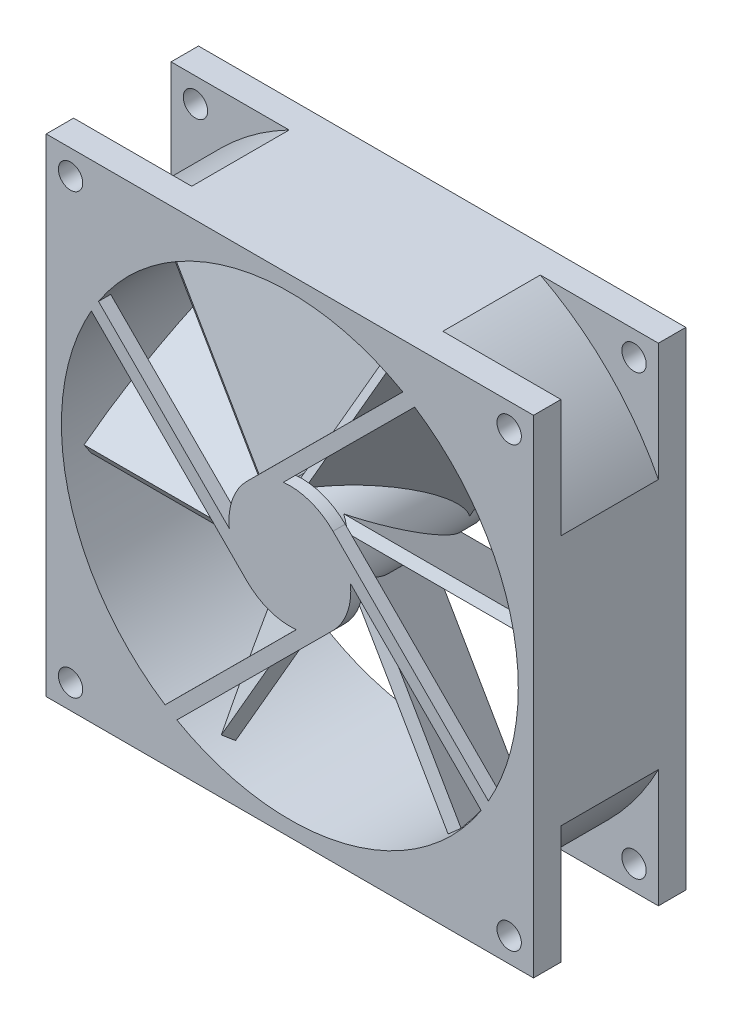
from build123d import *

# Parameters (mm, degrees)
SKETCH1_W                = 80
SKETCH1_H                = 80
SKETCH1_R                = 37.5
BOSS_EXTRUDE1_DEPTH      = 12.5
BOSS_EXTRUDE1_DEPTH_BACK = 12.5
SKETCH2_R                = 60
SKETCH2_R_2              = 45
CUT_EXTRUDE1_DEPTH       = 8
CUT_EXTRUDE1_DEPTH_BACK  = 8
SKETCH3_R                = 2
CUT_EXTRUDE2_DEPTH       = 26
SKETCH4_R                = 10
BOSS_EXTRUDE2_DEPTH      = 2
SKETCH5_R                = 7.5
BOSS_EXTRUDE3_DEPTH      = 23
BOSS_EXTRUDE9_START      = -17.942054
BOSS_EXTRUDE9_DEPTH      = 35.442054
CIRPATTERN1_COUNT        = 6


with BuildPart() as part:
    # Sketch1 → Boss-Extrude1 (new body, two sides)
    with BuildSketch(Plane.XY) as boss_extrude1_sk:
        Rectangle(SKETCH1_W, SKETCH1_H)
        Circle(SKETCH1_R, mode=Mode.SUBTRACT)
    extrude(amount=BOSS_EXTRUDE1_DEPTH)
    extrude(boss_extrude1_sk.sketch, amount=-BOSS_EXTRUDE1_DEPTH_BACK)

    # Sketch2 → Cut-Extrude1 (cut, two sides)
    with BuildSketch(Plane.XY) as cut_extrude1_sk:
        Circle(SKETCH2_R)
        Circle(SKETCH2_R_2, mode=Mode.SUBTRACT)
    extrude(amount=CUT_EXTRUDE1_DEPTH, mode=Mode.SUBTRACT)
    extrude(cut_extrude1_sk.sketch, amount=-CUT_EXTRUDE1_DEPTH_BACK, mode=Mode.SUBTRACT)

    # Sketch3 → Cut-Extrude2 (cut, through all)
    with BuildSketch(Plane.XY.offset(12.5)):
        with Locations((-36, 36)):
            Circle(SKETCH3_R)
        with Locations((36, 36)):
            Circle(SKETCH3_R)
        with Locations((36, -36)):
            Circle(SKETCH3_R)
        with Locations((-36, -36)):
            Circle(SKETCH3_R)
    extrude(amount=-CUT_EXTRUDE2_DEPTH, mode=Mode.SUBTRACT)

    # Sketch4 → Boss-Extrude2 (add)
    with BuildSketch(Plane.XY.offset(12.5)):
        with BuildLine():
            Line((18.549623759, 32.590818621), (-7.057093407, 7.085014654))
            ThreePointArc((-7.057093407, 7.085014654), (-4.306304625, 9.025283401), (-1.067547722, 9.942853809))
            Line((-1.067547722, 9.942853809), (20.484975285, 31.410440741))
            ThreePointArc((20.484975285, 31.410440741), (19.526220925, 32.015257244), (18.549623759, 32.590818621))
        make_face()
        Circle(SKETCH4_R)
        with BuildLine():
            ThreePointArc((-7.085014654, -7.057093407), (-9.025283401, -4.306304625), (-9.942853809, -1.067547722))
            Line((-9.942853809, -1.067547722), (-31.410440741, 20.484975285))
            ThreePointArc((-31.410440741, 20.484975285), (-32.015257244, 19.526220925), (-32.590818621, 18.549623759))
            Line((-32.590818621, 18.549623759), (-7.085014654, -7.057093407))
        make_face()
        with BuildLine():
            Line((32.590818621, -18.549623759), (7.085014654, 7.057093407))
            ThreePointArc((7.085014654, 7.057093407), (9.025283401, 4.306304625), (9.942853809, 1.067547722))
            Line((9.942853809, 1.067547722), (31.410440741, -20.484975285))
            ThreePointArc((31.410440741, -20.484975285), (32.015257244, -19.526220925), (32.590818621, -18.549623759))
        make_face()
        with BuildLine():
            ThreePointArc((7.057093407, -7.085014654), (4.306304625, -9.025283401), (1.067547722, -9.942853809))
            Line((1.067547722, -9.942853809), (-20.484975285, -31.410440741))
            ThreePointArc((-20.484975285, -31.410440741), (-19.526220925, -32.015257244), (-18.549623759, -32.590818621))
            Line((-18.549623759, -32.590818621), (7.057093407, -7.085014654))
        make_face()
    extrude(amount=-BOSS_EXTRUDE2_DEPTH)

    # Sketch5 → Boss-Extrude3 (add)
    with BuildSketch(Plane(origin=(0, 0, 10.5), x_dir=(-1, 0, 0), z_dir=(0, 0, -1))):
        Circle(SKETCH5_R)
    extrude(amount=BOSS_EXTRUDE3_DEPTH)

    # Sketch7 → Boss-Extrude9 (add)
    with BuildSketch(Plane(origin=(20, 0, 0), x_dir=(0, 0, -1), z_dir=(1, 0, 0)).offset(BOSS_EXTRUDE9_START)):
        Polygon((9.730274214, -7.212132837), (-9.063025071, 4.533679216), (-8.124052437, 6.03603543), (10.669246848, -5.709776623), align=None)
    boss_extrude9 = extrude(amount=BOSS_EXTRUDE9_DEPTH)

    # CirPattern1: Boss-Extrude9 ×6 about axis
    cirpattern1_axis = Axis((0, 0, 0), (0, 0, 1))
    for i in range(1, CIRPATTERN1_COUNT):
        add(boss_extrude9.rotate(cirpattern1_axis, i * 360 / CIRPATTERN1_COUNT))


solid = part.part
